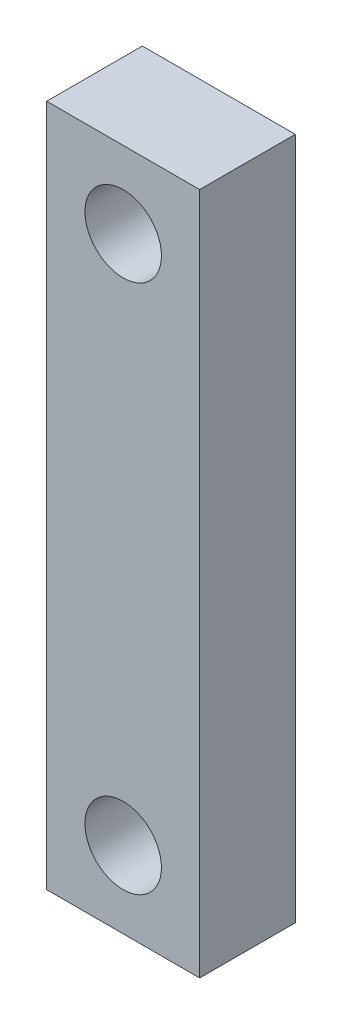
from build123d import *

# Parameters (mm, degrees)
SKETCH1_W      = 16
SKETCH1_H      = 71.4
BODY_DEPTH     = 5
SKETCH2_R      = 4
TOP_HOLE_DEPTH = 11


with BuildPart() as part:
    # Sketch1 → Body (new body, symmetric)
    with BuildSketch(Plane.XY):
        Rectangle(SKETCH1_W, SKETCH1_H)
    extrude(amount=BODY_DEPTH, both=True)

    # Sketch2 → Top Hole (cut, through all)
    with BuildSketch(Plane.XY.offset(5)):
        with Locations((0, 27.7)):
            Circle(SKETCH2_R)
    top_hole = extrude(amount=-TOP_HOLE_DEPTH, mode=Mode.SUBTRACT)

    # Bottom Hole: Top Hole across plane
    add(top_hole.mirror(Plane.ZX), mode=Mode.SUBTRACT)


solid = part.part
